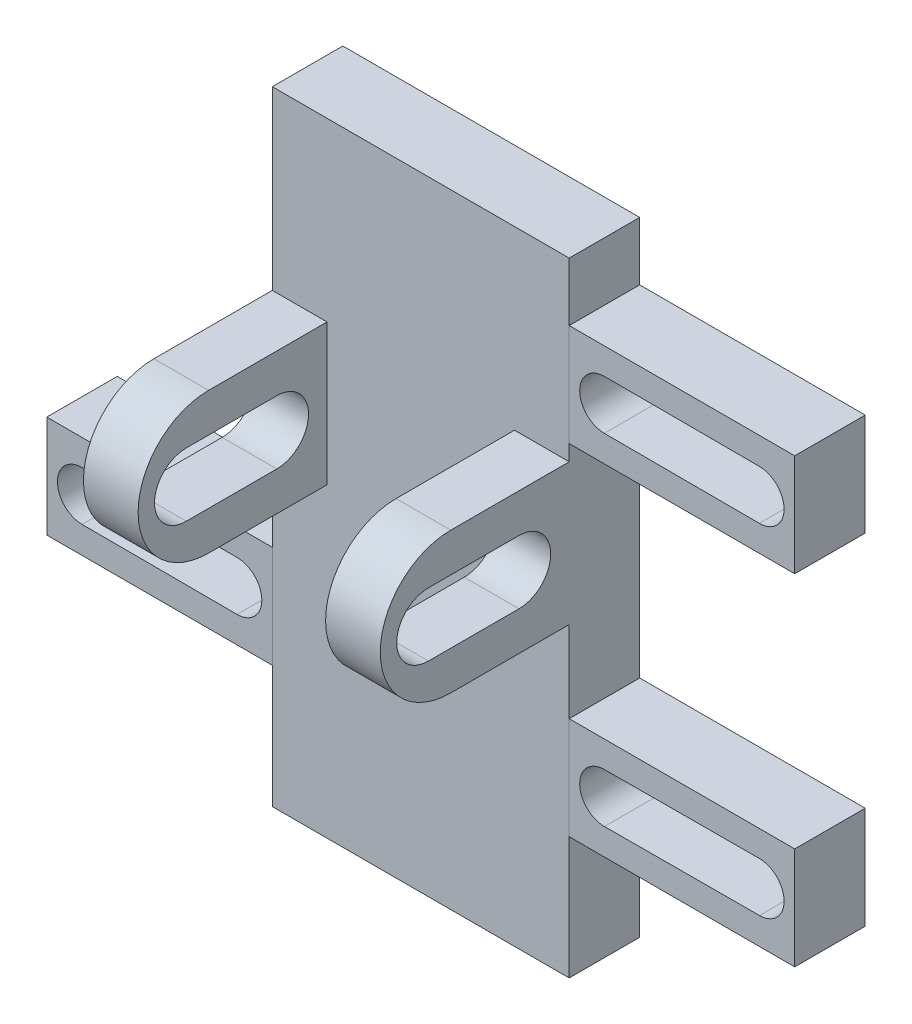
from build123d import *

# Parameters (mm, degrees)
SKETCH1_W           = 21.060518524
SKETCH1_H           = 44.229680595
BOSS_EXTRUDE1_DEPTH = 5
BOSS_EXTRUDE3_DEPTH = 3.8801
CUT_EXTRUDE1_DEPTH  = 8
SKETCH6_W           = 16
SKETCH6_H           = 7.25
BOSS_EXTRUDE4_DEPTH = 5
SKETCH11_W          = 16
SKETCH11_H          = 7.25
CUT_EXTRUDE2_DEPTH  = 5


with BuildPart() as part:
    # Sketch1 → Boss-Extrude1 (new body)
    with BuildSketch(Plane.XY):
        with Locations((4671.613089989, -40.729662913)):
            Rectangle(SKETCH1_W, SKETCH1_H)
    extrude(amount=BOSS_EXTRUDE1_DEPTH)

    # Sketch4 → Boss-Extrude3 (add)
    with BuildSketch(Plane.ZY.offset(-4661.082830727)):
        with BuildLine():
            Line((13.400549781, -31.129223835), (5, -31.129223835))
            Line((5, -31.129223835), (5, -41.129223835))
            Line((5, -41.129223835), (13.400549781, -41.129223835))
            ThreePointArc((13.400549781, -41.129223835), (18.400549781, -36.129223835), (13.400549781, -31.129223835))
        make_face()
    boss_extrude3 = extrude(amount=-BOSS_EXTRUDE3_DEPTH)

    # Sketch5 → Cut-Extrude1 (cut)
    with BuildSketch(Plane(origin=(4664.962930727, 0, 0), x_dir=(0, 0, -1), z_dir=(1, 0, 0))):
        with BuildLine():
            Line((-14.986353963, -33.879223835), (-8.563353453, -33.879223835))
            ThreePointArc((-8.563353453, -33.879223835), (-6.313353453, -36.129223835), (-8.563353453, -38.379223835))
            Line((-8.563353453, -38.379223835), (-14.986353963, -38.379223835))
            ThreePointArc((-14.986353963, -38.379223835), (-17.236353963, -36.129223835), (-14.986353963, -33.879223835))
        make_face()
    cut_extrude1 = extrude(amount=-CUT_EXTRUDE1_DEPTH, mode=Mode.SUBTRACT)

    # Mirror2: Boss-Extrude3, Cut-Extrude1 across plane
    add(boss_extrude3.mirror(Plane.ZY.offset(-4671.613089989)))
    add(cut_extrude1.mirror(Plane.ZY.offset(-4671.613089989)), mode=Mode.SUBTRACT)


with BuildPart() as body_2:
    # Sketch6 → Boss-Extrude4 (new body)
    with BuildSketch(Plane.XY.offset(5)):
        with Locations((4690.143349251, -50.538110101)):
            Rectangle(SKETCH6_W, SKETCH6_H)
        with BuildLine():
            Line((4695.643349251, -52.255506626), (4684.643397546, -52.288102418))
            ThreePointArc((4684.643397546, -52.288102418), (4682.888219535, -50.543295795), (4684.633026158, -48.788117784))
            Line((4684.633026158, -48.788117784), (4695.632977863, -48.755521993))
            ThreePointArc((4695.632977863, -48.755521993), (4697.388155873, -50.500328616), (4695.643349251, -52.255506626))
        make_face(mode=Mode.SUBTRACT)
    extrude(amount=-BOSS_EXTRUDE4_DEPTH)


with BuildPart() as body_3:
    # Mirror3: mirrored copy
    add(body_2.part.mirror(Plane.ZY.offset(-4671.613089989)))


with BuildPart() as body_4:
    # Mirror4: mirrored copy
    add(body_3.part.mirror(Plane(origin=(0, -38.461673776, 0), x_dir=(0, 0, 1), z_dir=(0, -1, 0))))

    # Sketch11 → Cut-Extrude2 (cut)
    with BuildSketch(Plane.XY.offset(5)):
        with Locations((4653.082830727, -26.385237452)):
            Rectangle(SKETCH11_W, SKETCH11_H)
    extrude(amount=-CUT_EXTRUDE2_DEPTH, mode=Mode.SUBTRACT)


with BuildPart() as body_5:
    # Mirror4 2: mirrored copy
    add(body_2.part.mirror(Plane(origin=(0, -38.461673776, 0), x_dir=(0, 0, 1), z_dir=(0, -1, 0))))


solid = Compound([part.part, body_2.part, body_3.part, body_5.part])
